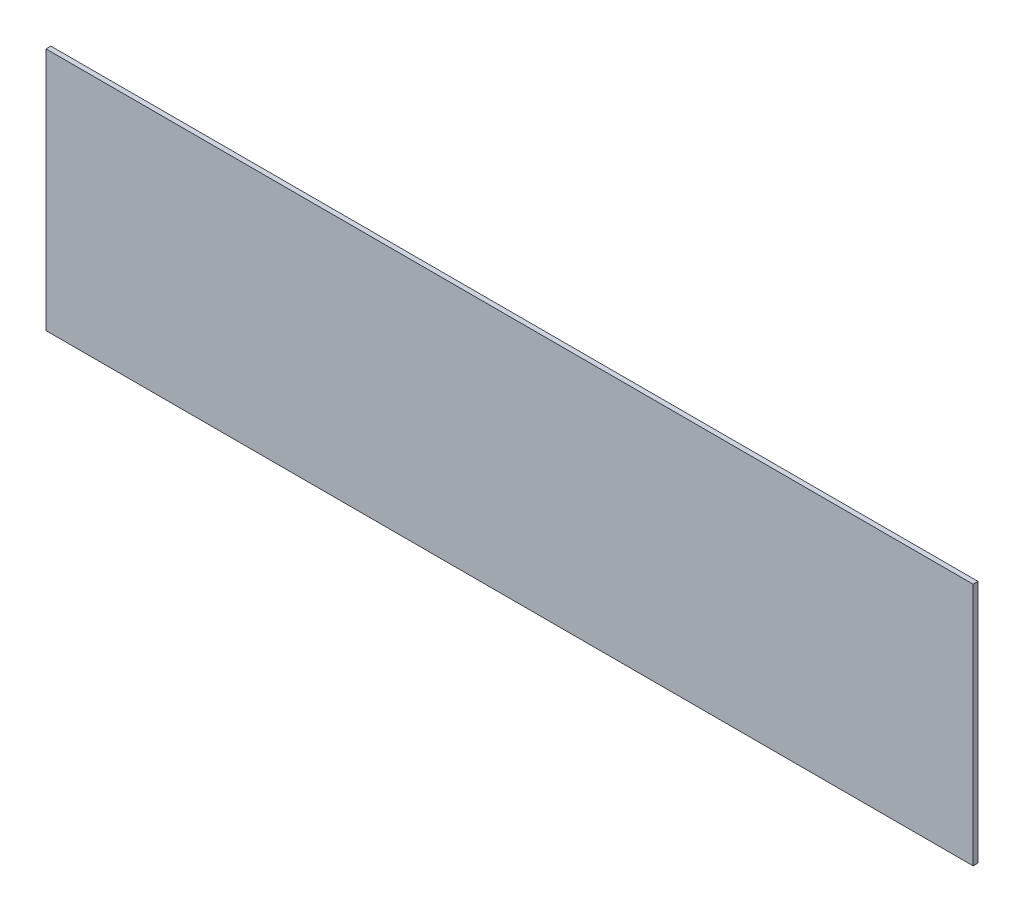
from build123d import *

# Parameters (mm, degrees)
SKETCH1_W           = 570
SKETCH1_H           = 150
BOSS_EXTRUDE1_DEPTH = 3


with BuildPart() as part:
    # Sketch1 → Boss-Extrude1 (new body)
    with BuildSketch(Plane.XY):
        Rectangle(SKETCH1_W, SKETCH1_H)
    extrude(amount=BOSS_EXTRUDE1_DEPTH)


solid = part.part
